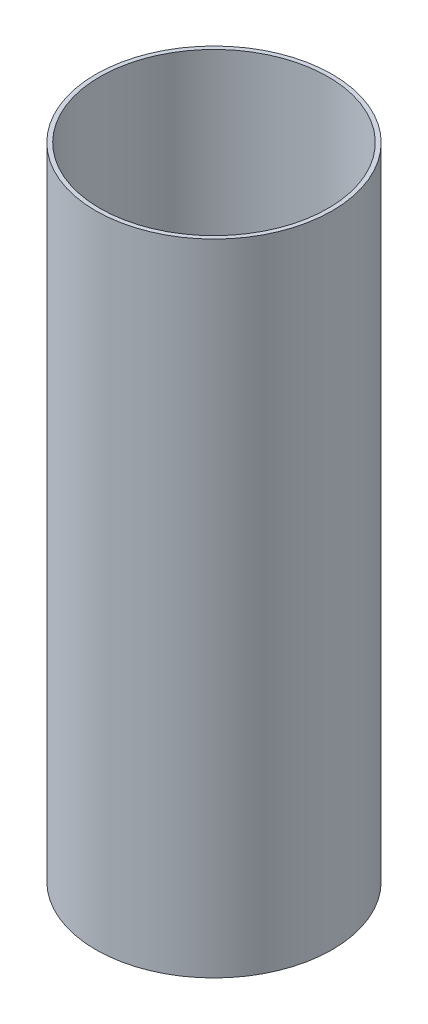
from build123d import *

# Parameters (mm, degrees)
SKETCH1_R           = 42.5
SKETCH1_R_2         = 41
BOSS_EXTRUDE1_DEPTH = 230


with BuildPart() as part:
    # Sketch1 → Boss-Extrude1 (new body)
    with BuildSketch(Plane(origin=(0, 0, 0), x_dir=(1, 0, 0), z_dir=(0, 1, 0))):
        Circle(SKETCH1_R)
        Circle(SKETCH1_R_2, mode=Mode.SUBTRACT)
    extrude(amount=BOSS_EXTRUDE1_DEPTH)


solid = part.part
